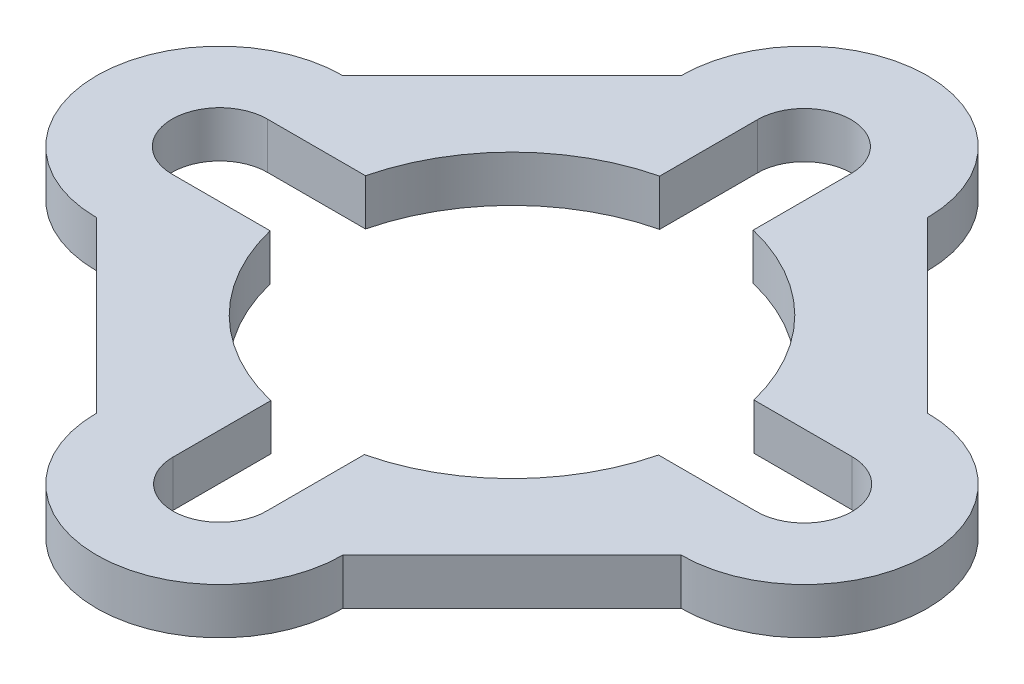
from build123d import *

# Parameters (mm, degrees)
BOSS_EXTRUDE1_DEPTH = 1.5


with BuildPart() as part:
    # Sketch10 → Boss-Extrude1 (new body)
    with BuildSketch(Plane(origin=(0, 0, 0), x_dir=(1, 0, 0), z_dir=(0, 1, 0))):
        with BuildLine():
            ThreePointArc((-9.5, 4), (-13.5, 0), (-9.5, -4))
            Line((-9.5, -4), (-4, -9.5))
            ThreePointArc((-4, -9.5), (0, -13.5), (4, -9.5))
            Line((4, -9.5), (9.5, -4))
            ThreePointArc((9.5, -4), (13.5, 0), (9.5, 4))
            Line((9.5, 4), (4, 9.5))
            ThreePointArc((4, 9.5), (0, 13.5), (-4, 9.5))
            Line((-4, 9.5), (-9.5, 4))
        make_face()
        with BuildLine():
            ThreePointArc((-9.5, -1.55), (-11.05, 0), (-9.5, 1.55))
            Line((-9.5, 1.55), (-6.312487624, 1.55))
            ThreePointArc((-6.312487624, 1.55), (-4.58526578, 4.607096453), (-1.52, 6.319778477))
            Line((-1.52, 6.319778477), (-1.52, 9.5))
            ThreePointArc((-1.52, 9.5), (0, 11.02), (1.52, 9.5))
            Line((1.52, 9.5), (1.52, 6.319778477))
            ThreePointArc((1.52, 6.319778477), (4.58526578, 4.607096453), (6.312487624, 1.55))
            Line((6.312487624, 1.55), (9.5, 1.55))
            ThreePointArc((9.5, 1.55), (11.05, 0), (9.5, -1.55))
            Line((9.5, -1.55), (6.312487624, -1.55))
            ThreePointArc((6.312487624, -1.55), (4.58526578, -4.607096453), (1.52, -6.319778477))
            Line((1.52, -6.319778477), (1.52, -9.5))
            ThreePointArc((1.52, -9.5), (0, -11.02), (-1.52, -9.5))
            Line((-1.52, -9.5), (-1.52, -6.319778477))
            ThreePointArc((-1.52, -6.319778477), (-4.58526578, -4.607096453), (-6.312487624, -1.55))
            Line((-6.312487624, -1.55), (-9.5, -1.55))
        make_face(mode=Mode.SUBTRACT)
    extrude(amount=BOSS_EXTRUDE1_DEPTH)


solid = part.part
